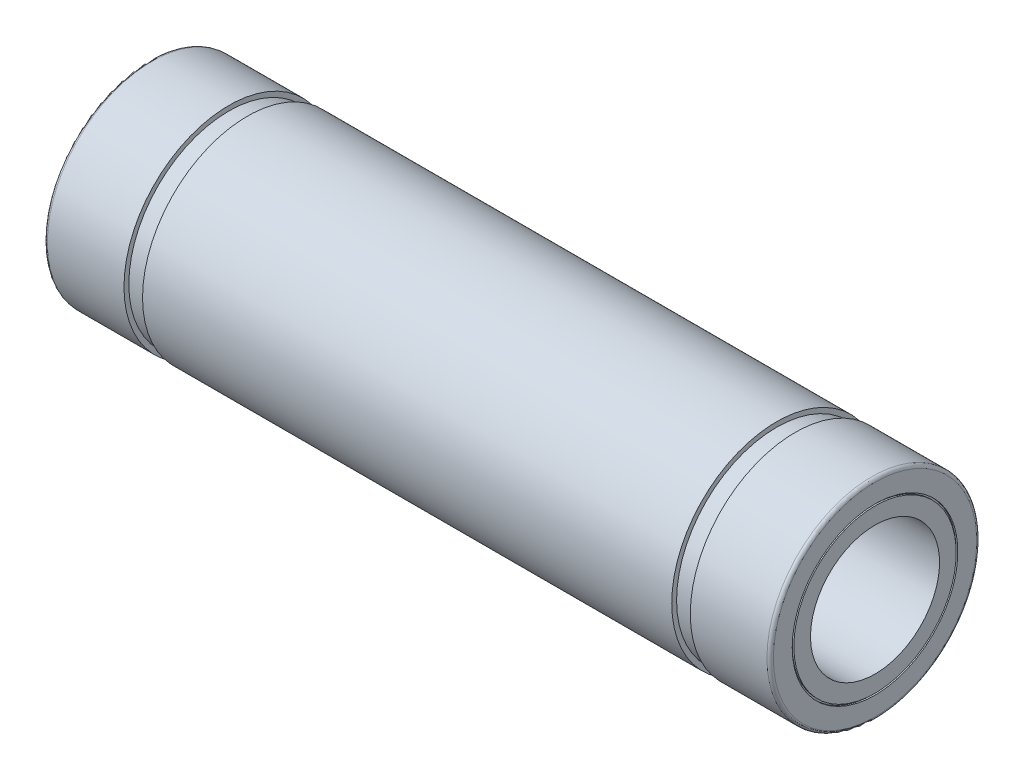
from build123d import *


with BuildPart() as part:
    # Sketch1 → Revolve1 (revolve)
    with BuildSketch(Plane(origin=(0, 0, 0), x_dir=(-1, 0, 0), z_dir=(0, 0, -1))):
        with BuildLine():
            Line((-22.4, 5.033333333), (-22.5, 5.033333333))
            Line((-22.5, 5.033333333), (-22.5, 4))
            Line((-22.5, 4), (22.5, 4))
            Line((22.5, 4), (22.5, 5.033333333))
            Line((22.5, 5.033333333), (22.4, 5.033333333))
            Line((22.4, 5.033333333), (22.4, 5.133333333))
            Line((22.4, 5.133333333), (22.5, 5.133333333))
            Line((22.5, 5.133333333), (22.5, 6.3))
            ThreePointArc((22.5, 6.3), (22.441421356, 6.441421356), (22.3, 6.5))
            Line((22.3, 6.5), (17.55, 6.5))
            Line((17.55, 6.5), (17.55, 6.2))
            Line((17.55, 6.2), (16.4, 6.2))
            Line((16.4, 6.2), (16.4, 6.5))
            Line((16.4, 6.5), (-16.4, 6.5))
            Line((-16.4, 6.5), (-16.4, 6.2))
            Line((-16.4, 6.2), (-17.55, 6.2))
            Line((-17.55, 6.2), (-17.55, 6.5))
            Line((-17.55, 6.5), (-22.3, 6.5))
            ThreePointArc((-22.3, 6.5), (-22.441421356, 6.441421356), (-22.5, 6.3))
            Line((-22.5, 6.3), (-22.5, 5.133333333))
            Line((-22.5, 5.133333333), (-22.4, 5.133333333))
            Line((-22.4, 5.133333333), (-22.4, 5.033333333))
        make_face()
    revolve(axis=Axis((22.5, 0, 0), (-1, 0, 0)))


solid = part.part
